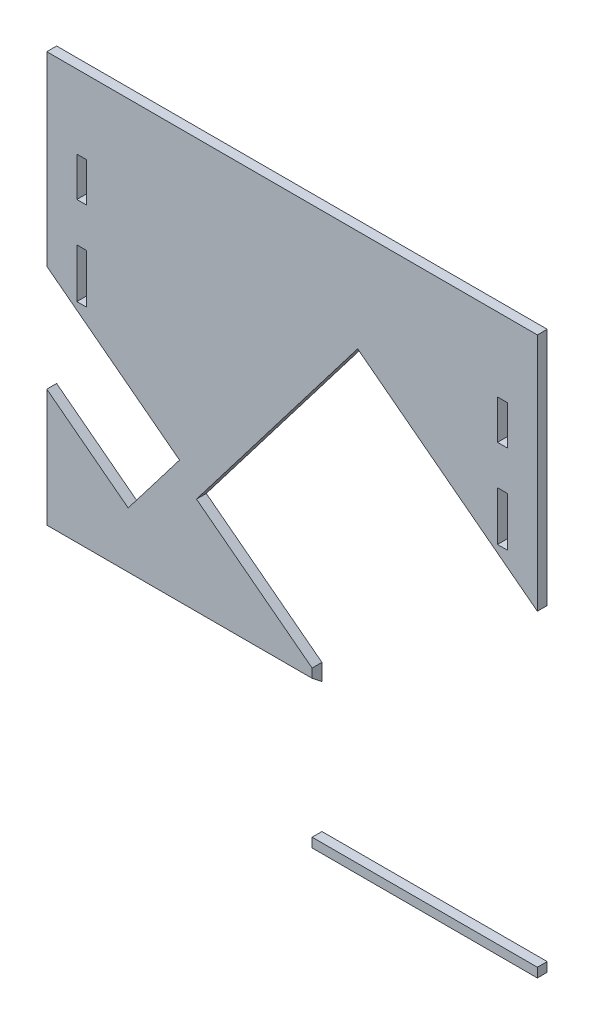
from build123d import *

# Parameters (mm, degrees)
SKETCH1_W           = 249.6
SKETCH1_H           = 283.36
BOSS_EXTRUDE1_DEPTH = 5
SKETCH3_W           = 135
SKETCH3_H           = 230.014345446
CUT_EXTRUDE1_DEPTH  = 193
CUT_EXTRUDE2_DEPTH  = 6
CUT_EXTRUDE3_DEPTH  = 6
SKETCH6_R           = 2.1
SKETCH6_R_2         = 4
CUT_EXTRUDE4_DEPTH  = 6
SKETCH7_W           = 5
SKETCH7_H           = 20
SKETCH7_H_2         = 25
CUT_EXTRUDE5_DEPTH  = 6


with BuildPart() as part:
    # Sketch1 → Boss-Extrude1 (new body)
    with BuildSketch(Plane.XY):
        with Locations((124.8, -141.68)):
            Rectangle(SKETCH1_W, SKETCH1_H)
    extrude(amount=BOSS_EXTRUDE1_DEPTH)

    # Sketch3 → Cut-Extrude1 (cut)
    with BuildSketch(Plane(origin=(0, -131.96972983, 103.10605305), x_dir=(1, 0, 0), z_dir=(0, 0.788010754, -0.615661475))):
        with Locations((67.5, 103.601456608)):
            Rectangle(SKETCH3_W, SKETCH3_H)
    extrude(amount=-CUT_EXTRUDE1_DEPTH, mode=Mode.SUBTRACT)

    # Sketch4 → Cut-Extrude2 (cut, through all)
    with BuildSketch(Plane.XY.offset(5)):
        Polygon((214.957001473, -95.278291976), (249.6, -121.767183305), (249.6, -278.612119258), (135, -278.612119258), (135, -204.083134422), (76.149175745, -159.084342324), (158.149444505, -51.841832454), align=None)
    extrude(amount=-CUT_EXTRUDE2_DEPTH, mode=Mode.SUBTRACT)

    # Sketch5 → Cut-Extrude3 (cut, through all)
    with BuildSketch(Plane.XY.offset(5)):
        Polygon((0, -94.564658056), (67.52306177, -146.194456905), (41.404457646, -180.353182271), (-26.118604124, -128.723383422), align=None)
    extrude(amount=-CUT_EXTRUDE3_DEPTH, mode=Mode.SUBTRACT)

    # Sketch6 → Cut-Extrude4 (cut, through all)
    with BuildSketch(Plane.XY.offset(5)):
        with Locations((763.495728001, -447.322738807)):
            Circle(SKETCH6_R)
        with Locations((787.807112022, -441.495509021)):
            Circle(SKETCH6_R)
        with Locations((793.634341808, -465.806893042)):
            Circle(SKETCH6_R)
        with Locations((769.322957787, -471.634122828)):
            Circle(SKETCH6_R)
        with Locations((797.713402658, -482.824861857)):
            Circle(SKETCH6_R)
        with Locations((773.402018637, -488.652091643)):
            Circle(SKETCH6_R)
        with Locations((784.392264691, -480.876199946)):
            Circle(SKETCH6_R_2)
        with Locations((778.565034905, -456.564815925)):
            Circle(SKETCH6_R_2)
    extrude(amount=-CUT_EXTRUDE4_DEPTH, mode=Mode.SUBTRACT)

    # Sketch7 → Cut-Extrude5 (cut, through all)
    with BuildSketch(Plane.XY.offset(5)):
        with Locations((17.788155616, -47.477871486)):
            Rectangle(SKETCH7_W, SKETCH7_H)
        with Locations((231.811844384, -47.477871486)):
            Rectangle(SKETCH7_W, SKETCH7_H)
        with Locations((17.788155616, -89.977871486)):
            Rectangle(SKETCH7_W, SKETCH7_H_2)
        with Locations((231.811844384, -89.977871486)):
            Rectangle(SKETCH7_W, SKETCH7_H_2)
    extrude(amount=-CUT_EXTRUDE5_DEPTH, mode=Mode.SUBTRACT)


solid = part.part
